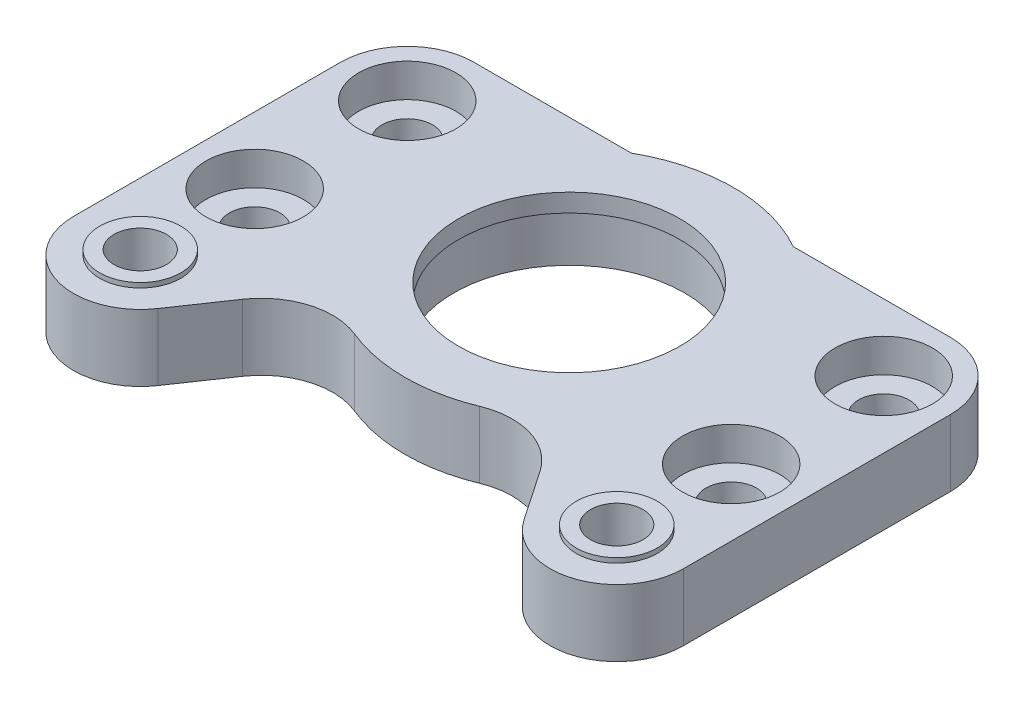
from build123d import *

# Parameters (mm, degrees)
SKETCH_1_R          = 2.65
SKETCH_1_R_2        = 2.75
SKETCH_1_R_3        = 12.1
EXTRUDE_1_DEPTH     = 7
EXTRUDE_START       = -7
SKETCH_2_R          = 12.1
SKETCH_2_R_2        = 11.6
EXTRUDE_2_DEPTH     = 1.9
SKETCH_3_R          = 5.1
SKETCH_3_R_2        = 2.65
CUT_EXTRUDE_1_DEPTH = 3.5
SKETCH_4_R          = 4.25
SKETCH_4_R_2        = 2.75
EXTRUDE_3_DEPTH     = 0.5


with BuildPart() as part:
    # 草图1 → 凸台-拉伸1 (new body)
    with BuildSketch(Plane(origin=(0, 0, 0), x_dir=(1, 0, 0), z_dir=(0, 1, 0))):
        with BuildLine():
            Line((40.480150219, 0), (56.971640332, 0))
            ThreePointArc((56.971640332, 0), (61.9213878, -2.050252532), (63.971640332, -7))
            Line((63.971640332, -7), (63.971640332, -35))
            ThreePointArc((63.971640332, -35), (59.032841716, -41.689652372), (51.185512088, -38.939634494))
            Line((51.185512088, -38.939634494), (47.590395779, -33.659498976))
            ThreePointArc((47.590395779, -33.659498976), (43.546468384, -30.69695478), (38.539560652, -30.94371753))
            ThreePointArc((38.539560652, -30.94371753), (31.985820166, -32.238145), (25.43207968, -30.94371753))
            ThreePointArc((25.43207968, -30.94371753), (20.425171948, -30.69695478), (16.381244554, -33.659498976))
            Line((16.381244554, -33.659498976), (12.786128244, -38.939634494))
            ThreePointArc((12.786128244, -38.939634494), (4.938798616, -41.689652372), (0, -35))
            Line((0, -35), (0, -7))
            ThreePointArc((0, -7), (2.050252532, -2.050252532), (7, 0))
            Line((7, 0), (23.491490114, 0))
            ThreePointArc((23.491490114, 0), (31.985820166, 2.238145), (40.480150219, 0))
        make_face()
        with Locations((56.971640332, -7)):
            Circle(SKETCH_1_R, mode=Mode.SUBTRACT)
        with Locations((56.971640332, -35)):
            Circle(SKETCH_1_R_2, mode=Mode.SUBTRACT)
        with Locations((7, -23)):
            Circle(SKETCH_1_R, mode=Mode.SUBTRACT)
        with Locations((7, -7)):
            Circle(SKETCH_1_R, mode=Mode.SUBTRACT)
        with Locations((7, -35)):
            Circle(SKETCH_1_R_2, mode=Mode.SUBTRACT)
        with Locations((56.971640332, -23)):
            Circle(SKETCH_1_R, mode=Mode.SUBTRACT)
        with Locations((31.985820166, -15)):
            Circle(SKETCH_1_R_3, mode=Mode.SUBTRACT)
    extrude(amount=EXTRUDE_1_DEPTH)

    # 草图2 → 凸台-拉伸2 (add)
    with BuildSketch(Plane.XZ.offset(EXTRUDE_START)):
        with Locations((31.985820166, 15)):
            Circle(SKETCH_2_R)
        with Locations((31.985820166, 15)):
            Circle(SKETCH_2_R_2, mode=Mode.SUBTRACT)
    extrude(amount=EXTRUDE_2_DEPTH)

    # 草图3 → 切除-拉伸1 (cut)
    with BuildSketch(Plane(origin=(0, 7, 0), x_dir=(1, 0, 0), z_dir=(0, 1, 0))):
        with Locations((56.971640332, -7)):
            Circle(SKETCH_3_R)
        with Locations((56.971640332, -23)):
            Circle(SKETCH_3_R)
        with Locations((7, -23)):
            Circle(SKETCH_3_R)
        with Locations((7, -7)):
            Circle(SKETCH_3_R)
        with Locations((7, -7)):
            Circle(SKETCH_3_R_2, mode=Mode.SUBTRACT)
    extrude(amount=-CUT_EXTRUDE_1_DEPTH, mode=Mode.SUBTRACT)

    # 草图4 → 凸台-拉伸3 (add)
    with BuildSketch(Plane(origin=(0, 7, 0), x_dir=(1, 0, 0), z_dir=(0, 1, 0))):
        with Locations((7, -35)):
            Circle(SKETCH_4_R)
        with Locations((7, -35)):
            Circle(SKETCH_4_R_2, mode=Mode.SUBTRACT)
        with Locations((56.971640332, -35)):
            Circle(SKETCH_4_R)
        with Locations((56.971640332, -35)):
            Circle(SKETCH_4_R_2, mode=Mode.SUBTRACT)
    extrude(amount=EXTRUDE_3_DEPTH)

    # 草图5 → 切除-旋转1 (revolve, cut)
    with BuildSketch(Plane.XY.offset(35)):
        Polygon((12, 0), (9.65, 3.5), (7, 3.5), (7, 0), align=None)
    cut_revolve_1 = revolve(axis=Axis((7, 0, 35), (0, 1, 0)), mode=Mode.SUBTRACT)

    # 镜向1: 切除-旋转1 across plane
    add(cut_revolve_1.mirror(Plane.ZY.offset(-31.985820166)), mode=Mode.SUBTRACT)


solid = part.part
